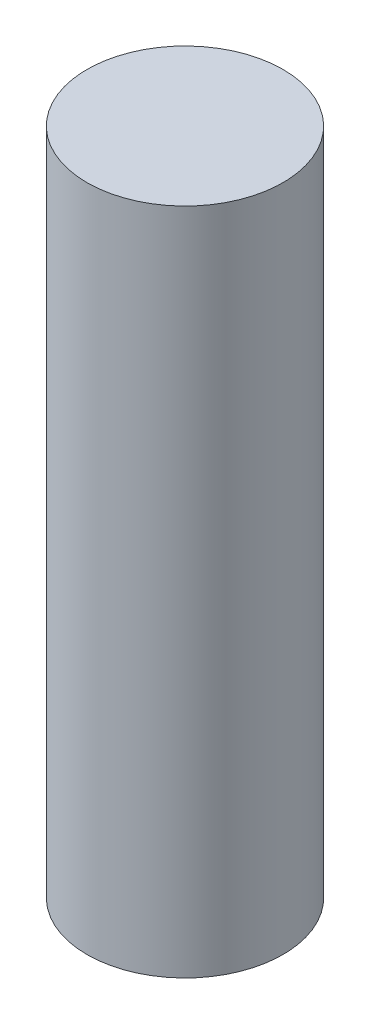
from build123d import *

# Parameters (mm, degrees)
SKETCH1_R           = 6.6
BOSS_EXTRUDE1_DEPTH = 45


with BuildPart() as part:
    # Sketch1 → Boss-Extrude1 (new body)
    with BuildSketch(Plane(origin=(0, 0, 0), x_dir=(1, 0, 0), z_dir=(0, 1, 0))):
        Circle(SKETCH1_R)
    extrude(amount=BOSS_EXTRUDE1_DEPTH)


solid = part.part
